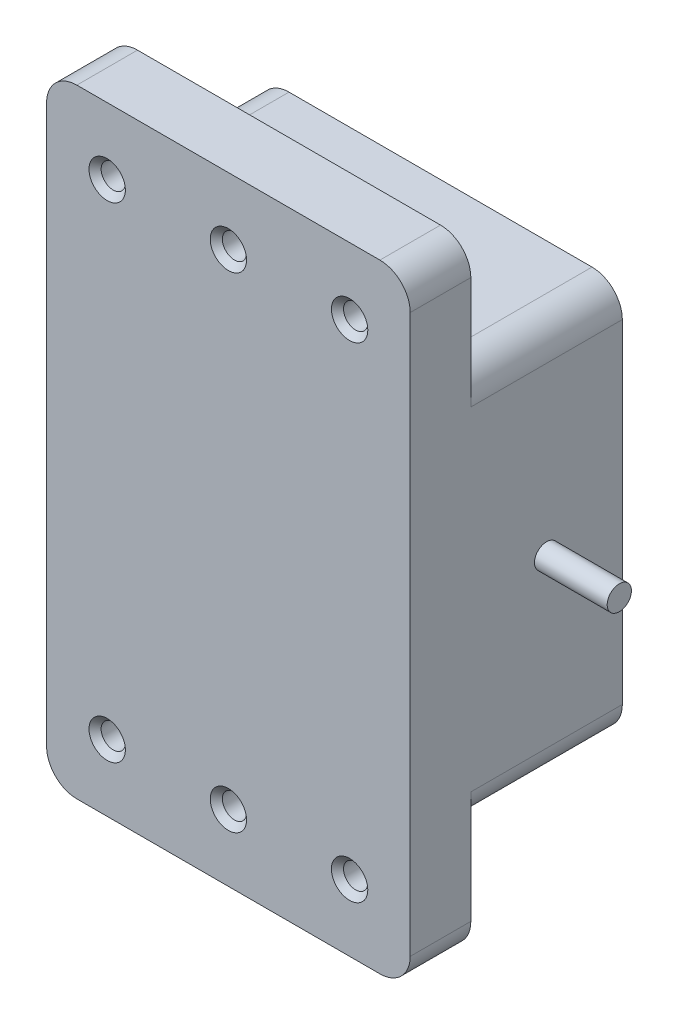
from build123d import *

# Parameters (mm, degrees)
SKETCH3_W           = 60
SKETCH3_H           = 102
SKETCH3_R           = 2
BOSS_EXTRUDE1_DEPTH = 10
SKETCH4_W           = 60
SKETCH4_H           = 65
BOSS_EXTRUDE2_DEPTH = 25
FILLET1_R           = 5
SKETCH6_W           = 3.461538462
SKETCH6_H           = 1.666666666
CUT_EXTRUDE1_DEPTH  = 2
SKETCH7_R           = 2
BOSS_EXTRUDE3_DEPTH = 12
SKETCH8_R           = 2
BOSS_EXTRUDE4_DEPTH = 12
CHAMFER2_SIZE       = 1


with BuildPart() as part:
    # Sketch3 → Boss-Extrude1 (new body)
    with BuildSketch(Plane.XY):
        Rectangle(SKETCH3_W, SKETCH3_H)
        with Locations((-20, 40)):
            Circle(SKETCH3_R, mode=Mode.SUBTRACT)
        with Locations((20, 40)):
            Circle(SKETCH3_R, mode=Mode.SUBTRACT)
        with Locations((20, -40)):
            Circle(SKETCH3_R, mode=Mode.SUBTRACT)
        with Locations((-20, -40)):
            Circle(SKETCH3_R, mode=Mode.SUBTRACT)
        with Locations((0, 40)):
            Circle(SKETCH3_R, mode=Mode.SUBTRACT)
        with Locations((0, -40)):
            Circle(SKETCH3_R, mode=Mode.SUBTRACT)
    extrude(amount=BOSS_EXTRUDE1_DEPTH)

    # Sketch4 → Boss-Extrude2 (add)
    with BuildSketch(Plane(origin=(0, 0, 0), x_dir=(-1, 0, 0), z_dir=(0, 0, -1))):
        Rectangle(SKETCH4_W, SKETCH4_H)
    extrude(amount=BOSS_EXTRUDE2_DEPTH)

    # Fillet1
    fillet1_edges = [part.edges().sort_by_distance(p)[0] for p in [
        (30, -32.5, -12.5),
        (-30, -32.5, -12.5),
        (-30, 32.5, -12.5),
        (30, 32.5, -12.5),
        (30, -51, 5),
        (-30, -51, 5),
        (-30, 51, 5),
        (30, 51, 5),
    ]]
    fillet(fillet1_edges, radius=FILLET1_R)

    # Sketch6 → Cut-Extrude1 (cut)
    with BuildSketch(Plane(origin=(0, 0, -25), x_dir=(-1, 0, 0), z_dir=(0, 0, -1))):
        Polygon((-27.221554487, 5), (-25.358573718, 5), (-23.076923077, -1.975160256), (-20.779246795, 5), (-18.934294872, 5), (-17.243589744, -5), (-19.060496795, -5), (-20.128205128, 1.316105769), (-22.207532051, -5), (-23.958333333, -5), (-26.025641026, 1.316105769), (-27.091346154, -5), (-28.91025641, -5), align=None)
        Polygon((-15.576923077, 5), (-13.782051282, 5), (-13.782051282, -3.205128205), (-10.961538462, -3.205128205), (-10.961538462, -5), (-15.576923077, -5), align=None)
        Polygon((-6.344150641, 5), (-4.679487179, 5), (-0.641025641, -5), (-2.558092949, -5), (-3.335336538, -2.948717949), (-7.692307692, -2.948717949), (-8.469551282, -5), (-10.384615385, -5), align=None)
        Polygon((-5.512820513, 2.317708333), (-7.011217949, -1.153846154), (-4.014423077, -1.153846154), align=None, mode=Mode.SUBTRACT)
        with Locations((2.564102564, -1.346153846)):
            Rectangle(SKETCH6_W, SKETCH6_H)
        with BuildLine():
            Line((8.141025641, 2.564102564), (6.346153846, 2.564102564))
            add(Edge.make_bspline(
                [(6.346153846, 2.564102564), (6.358826324, 2.653821802), (6.383669876, 2.829710425), (6.443117175, 3.084353334), (6.51422256, 3.325899561), (6.602994, 3.553584178), (6.707108457, 3.767812766), (6.825507203, 3.969320453), (6.959470174, 4.157242331), (7.06215421, 4.270447216), (7.11338141, 4.326923077)],
                knots=[0, 0, 0, 0, 0.000271706, 0.000532661, 0.00078363, 0.001026547, 0.001264861, 0.001497449, 0.001727058, 0.001955643, 0.001955643, 0.001955643, 0.001955643], degree=3))
            add(Edge.make_bspline(
                [(7.11338141, 4.326923077), (7.187269858, 4.401438883), (7.332896225, 4.548301705), (7.576254962, 4.736416757), (7.831339862, 4.899217542), (8.103266763, 5.028287182), (8.387804278, 5.132754103), (8.687215149, 5.202924769), (9.000275873, 5.249483626), (9.213900433, 5.254069836), (9.322916667, 5.256410256)],
                knots=[0, 0, 0, 0, 0.00031451, 0.000619865, 0.00092054, 0.001220686, 0.001521047, 0.001828113, 0.002141722, 0.002468545, 0.002468545, 0.002468545, 0.002468545], degree=3))
            add(Edge.make_bspline(
                [(9.322916667, 5.256410256), (9.419837707, 5.254122141), (9.610364943, 5.249624166), (9.890392039, 5.213516866), (10.157374441, 5.150188683), (10.41413423, 5.067388504), (10.656895307, 4.954725023), (10.891015643, 4.823946701), (11.109953909, 4.663541655), (11.314222379, 4.482300095), (11.501881927, 4.286269605), (11.664395918, 4.076729133), (11.804112112, 3.859275988), (11.919219775, 3.632103545), (12.007721927, 3.394827401), (12.069145044, 3.148818268), (12.109347966, 2.894618984), (12.113353228, 2.721843154), (12.115384615, 2.634214744)],
                knots=[0, 0, 0, 0, 0.000290713, 0.000571484, 0.000845052, 0.00111301, 0.001379263, 0.001646614, 0.001916281, 0.002191603, 0.002465076, 0.002729142, 0.002985873, 0.003239403, 0.00349168, 0.003743837, 0.003999094, 0.004261789, 0.004261789, 0.004261789, 0.004261789], degree=3))
            add(Edge.make_bspline(
                [(12.115384615, 2.634214744), (12.111216086, 2.525694254), (12.103009534, 2.312050773), (12.035668833, 1.999367667), (11.930262324, 1.700386816), (11.77799237, 1.419291414), (11.587616144, 1.156846443), (11.354030891, 0.921826227), (11.083889725, 0.710545967), (10.881091154, 0.59700393), (10.77724359, 0.538862179)],
                knots=[0, 0, 0, 0, 0.000325266, 0.00064035, 0.000955261, 0.001273418, 0.001595958, 0.001924594, 0.002264384, 0.002620988, 0.002620988, 0.002620988, 0.002620988], degree=3))
            add(Edge.make_bspline(
                [(10.77724359, 0.538862179), (10.848522965, 0.51545966), (10.988583739, 0.469474759), (11.18766329, 0.378908016), (11.376965194, 0.279933578), (11.553229741, 0.164951371), (11.718210095, 0.038610767), (11.870900517, -0.10016824), (12.012213295, -0.251083047), (12.139841556, -0.414963628), (12.253116625, -0.589189032), (12.354752312, -0.769734755), (12.438404148, -0.959338807), (12.509267668, -1.15583578), (12.563219117, -1.360991686), (12.601205758, -1.574011564), (12.623162969, -1.7944095), (12.626511818, -1.943728968), (12.628205128, -2.019230769)],
                knots=[0, 0, 0, 0, 0.000224904, 0.000441926, 0.000655208, 0.00086524, 0.001072385, 0.001278014, 0.001483525, 0.001691897, 0.00190025, 0.002106492, 0.002312735, 0.002521193, 0.002732558, 0.002948282, 0.003169733, 0.003396237, 0.003396237, 0.003396237, 0.003396237], degree=3))
            add(Edge.make_bspline(
                [(12.628205128, -2.019230769), (12.624772561, -2.130187762), (12.618004239, -2.348972354), (12.574974411, -2.671219668), (12.494860625, -2.978453852), (12.389466501, -3.274210098), (12.248882179, -3.554670302), (12.083438067, -3.826270641), (11.880074011, -4.079592092), (11.654069782, -4.321331816), (11.40307891, -4.54111075), (11.130963973, -4.731649195), (10.843708544, -4.895165082), (10.539495241, -5.027911938), (10.218429753, -5.130142199), (9.881227708, -5.204038944), (9.526472274, -5.249250196), (9.284323935, -5.253989738), (9.160657051, -5.256410256)],
                knots=[0, 0, 0, 0, 0.000332918, 0.000656446, 0.000972737, 0.00128388, 0.00159654, 0.001912291, 0.002236099, 0.002569119, 0.002904176, 0.003234856, 0.003564077, 0.003894193, 0.004228686, 0.00457329, 0.004928598, 0.005299456, 0.005299456, 0.005299456, 0.005299456], degree=3))
            add(Edge.make_bspline(
                [(9.160657051, -5.256410256), (9.043670174, -5.253858229), (8.814917815, -5.248868078), (8.480319616, -5.205675789), (8.162315699, -5.136003121), (7.860094514, -5.037793719), (7.574825329, -4.910432908), (7.303921214, -4.758774758), (7.052788001, -4.574071982), (6.818627569, -4.36466241), (6.606634306, -4.12971676), (6.417162251, -3.874677432), (6.254389298, -3.598574616), (6.117647912, -3.302587938), (6.008007102, -2.986198148), (5.921522752, -2.650048641), (5.861112019, -2.293482685), (5.842713803, -2.048157722), (5.833333333, -1.923076923)],
                knots=[0, 0, 0, 0, 0.000350841, 0.000686024, 0.001010203, 0.001326309, 0.001637503, 0.001946101, 0.002255828, 0.002570745, 0.002887004, 0.003203517, 0.003522335, 0.003846787, 0.00418003, 0.004525477, 0.004887076, 0.00526322, 0.00526322, 0.00526322, 0.00526322], degree=3))
            Line((5.833333333, -1.923076923), (7.628205128, -1.923076923))
            add(Edge.make_bspline(
                [(7.628205128, -1.923076923), (7.639579044, -1.985969191), (7.661732727, -2.108468375), (7.704942127, -2.285819962), (7.761250003, -2.449526431), (7.826355918, -2.6010428), (7.896680108, -2.742358427), (7.981648545, -2.868254176), (8.075035191, -2.982148633), (8.209792801, -3.117547618), (8.402438087, -3.256664424), (8.662573045, -3.377563545), (8.951948551, -3.448425284), (9.15425089, -3.457070199), (9.258814103, -3.461538462)],
                knots=[0, 0, 0, 0, 0.000191723, 0.00037343, 0.000547005, 0.000710349, 0.000868031, 0.001019707, 0.00116488, 0.001309361, 0.001591842, 0.001872362, 0.00216533, 0.002478753, 0.002478753, 0.002478753, 0.002478753], degree=3))
            add(Edge.make_bspline(
                [(9.258814103, -3.461538462), (9.314299039, -3.460586987), (9.422981617, -3.458723261), (9.582620141, -3.438066358), (9.734698312, -3.404044422), (9.879499384, -3.357809872), (10.017945169, -3.299851973), (10.147390523, -3.22511873), (10.270473864, -3.138230667), (10.385857166, -3.040545418), (10.492473715, -2.934103464), (10.581184953, -2.816237085), (10.662260606, -2.696463778), (10.722224743, -2.566947549), (10.774766245, -2.434657757), (10.806924329, -2.294792697), (10.831205991, -2.15028636), (10.832617144, -2.051392567), (10.833333333, -2.001201923)],
                knots=[0, 0, 0, 0, 0.000166375, 0.000325891, 0.000481896, 0.000633307, 0.000781396, 0.000931222, 0.001080726, 0.001232824, 0.001384394, 0.001531449, 0.001674801, 0.001817254, 0.001958632, 0.002100987, 0.002246891, 0.002397252, 0.002397252, 0.002397252, 0.002397252], degree=3))
            add(Edge.make_bspline(
                [(10.833333333, -2.001201923), (10.831431985, -1.946309903), (10.827646836, -1.837032468), (10.796721775, -1.677565029), (10.747884566, -1.524170206), (10.680043718, -1.377527302), (10.589449827, -1.238176814), (10.482550045, -1.103322949), (10.350922439, -0.979984611), (10.206509327, -0.858068402), (10.03904685, -0.751794237), (9.856690664, -0.653718798), (9.654648168, -0.575681027), (9.437851399, -0.505978843), (9.202199442, -0.45506945), (8.94915561, -0.418104269), (8.6791281, -0.390589421), (8.492994627, -0.386641963), (8.397435897, -0.384615385)],
                knots=[0, 0, 0, 0, 0.000164568, 0.000327617, 0.000485362, 0.000646679, 0.000810612, 0.000982992, 0.001161491, 0.001350781, 0.001549139, 0.001755235, 0.001970987, 0.002197801, 0.002437893, 0.002693151, 0.002964834, 0.003251468, 0.003251468, 0.003251468, 0.003251468], degree=3))
            Line((8.397435897, -0.384615385), (8.397435897, 1.282051282))
            add(Edge.make_bspline(
                [(8.397435897, 1.282051282), (8.516412199, 1.292183685), (8.738993298, 1.311139403), (9.047947797, 1.35546801), (9.30804766, 1.414720491), (9.52554439, 1.486205403), (9.706139739, 1.578010653), (9.863906839, 1.679359596), (9.999783328, 1.797061581), (10.114617189, 1.927606751), (10.206480704, 2.067800022), (10.271496349, 2.215462376), (10.314429283, 2.366024956), (10.318497176, 2.469005223), (10.320512821, 2.520032051)],
                knots=[0, 0, 0, 0, 0.000358193, 0.000670108, 0.000935418, 0.001157773, 0.001354863, 0.001541548, 0.001719066, 0.001892248, 0.002061717, 0.002219552, 0.002375042, 0.002527759, 0.002527759, 0.002527759, 0.002527759], degree=3))
            add(Edge.make_bspline(
                [(10.320512821, 2.520032051), (10.317035256, 2.585136744), (10.310247787, 2.71220732), (10.257532624, 2.894072083), (10.166025073, 3.056189446), (10.043329515, 3.198218268), (9.893820712, 3.316851385), (9.718570185, 3.402977005), (9.521380882, 3.453579652), (9.382647582, 3.458825442), (9.310897436, 3.461538462)],
                knots=[0, 0, 0, 0, 0.000195145, 0.000380883, 0.000562026, 0.000749537, 0.000940694, 0.001130618, 0.001331279, 0.00154622, 0.00154622, 0.00154622, 0.00154622], degree=3))
            add(Edge.make_bspline(
                [(9.310897436, 3.461538462), (9.245863995, 3.458337384), (9.11681773, 3.451985465), (8.928113466, 3.404576425), (8.748907284, 3.324769206), (8.582910039, 3.214719755), (8.432517936, 3.082555029), (8.309089409, 2.926033344), (8.206427412, 2.754532186), (8.162911696, 2.62782795), (8.141025641, 2.564102564)],
                knots=[0, 0, 0, 0, 0.000194971, 0.000386881, 0.0005797, 0.00078083, 0.000982289, 0.001177506, 0.001376783, 0.001578421, 0.001578421, 0.001578421, 0.001578421], degree=3))
        make_face()
        with BuildLine():
            add(Edge.make_bspline(
                [(16.893028846, 5.256410256), (16.979908091, 5.25512051), (17.150735898, 5.252584523), (17.402333102, 5.225117718), (17.644690772, 5.183623037), (17.87875704, 5.125752427), (18.102847075, 5.049162735), (18.31859185, 4.957486187), (18.523423378, 4.845914159), (18.719953914, 4.719887823), (18.908107757, 4.577208144), (19.083362758, 4.414545944), (19.248919448, 4.235644086), (19.401194133, 4.037797895), (19.543558983, 3.822806991), (19.675546211, 3.590637284), (19.796145421, 3.34015246), (19.906708244, 3.070900497), (20.005573869, 2.778845426), (20.088848263, 2.460637248), (20.16026999, 2.116203294), (20.220554967, 1.744686217), (20.266120666, 1.345592182), (20.296832864, 0.919186326), (20.317909028, 0.466290698), (20.319629118, 0.155608018), (20.320512821, -0.00400641)],
                knots=[0, 0, 0, 0, 0.00026054, 0.000512291, 0.000758302, 0.000997826, 0.001234746, 0.001468058, 0.001700196, 0.001933576, 0.002167959, 0.00240755, 0.002649971, 0.002898401, 0.003155639, 0.00342299, 0.003698938, 0.003989099, 0.0042957, 0.004623198, 0.004975216, 0.00535065, 0.005751941, 0.006179826, 0.006632994, 0.007111797, 0.007111797, 0.007111797, 0.007111797], degree=3))
            add(Edge.make_bspline(
                [(20.320512821, -0.00400641), (20.319557777, -0.165617794), (20.317702144, -0.479625815), (20.297709006, -0.936663857), (20.263279879, -1.366165675), (20.218905135, -1.768086835), (20.158123874, -2.142215088), (20.086940569, -2.489519175), (20.002351714, -2.809873207), (19.900229486, -3.102555358), (19.790335903, -3.372280186), (19.669406802, -3.622276625), (19.53954996, -3.853221803), (19.403743902, -4.068599844), (19.254543241, -4.26206151), (19.099209994, -4.440185512), (18.930980672, -4.596186876), (18.756938381, -4.738105214), (18.570707249, -4.860751138), (18.374207827, -4.968015241), (18.163936873, -5.055019168), (17.943727267, -5.130690538), (17.709825493, -5.185014416), (17.465948218, -5.228118628), (17.209342117, -5.251940659), (17.034634347, -5.254895939), (16.945112179, -5.256410256)],
                knots=[0, 0, 0, 0, 0.000484813, 0.000941983, 0.001372019, 0.001777291, 0.002154702, 0.002508681, 0.002840566, 0.003147815, 0.003437976, 0.003713924, 0.00398029, 0.004232567, 0.004476966, 0.004712528, 0.004940691, 0.005164379, 0.005385504, 0.005608688, 0.0058349, 0.006067384, 0.006306429, 0.006554414, 0.006809954, 0.007078503, 0.007078503, 0.007078503, 0.007078503], degree=3))
            add(Edge.make_bspline(
                [(16.945112179, -5.256410256), (16.855592428, -5.254866729), (16.680224552, -5.25184298), (16.422924562, -5.228295755), (16.17775486, -5.1848398), (15.942002547, -5.130273479), (15.717308423, -5.055186599), (15.502595085, -4.965579576), (15.299513494, -4.858984748), (15.107501348, -4.73605307), (14.927214232, -4.595084274), (14.755850485, -4.437586177), (14.593789173, -4.263957998), (14.443495652, -4.072254957), (14.302508547, -3.865035889), (14.172298132, -3.639934455), (14.052942659, -3.397278396), (13.940708667, -3.136729474), (13.843191535, -2.852678371), (13.756405816, -2.542588545), (13.685313237, -2.203875143), (13.628135828, -1.836646979), (13.582485418, -1.441682043), (13.548526759, -1.018789697), (13.528422569, -0.567772966), (13.526586397, -0.257766701), (13.525641026, -0.098157051)],
                knots=[0, 0, 0, 0, 0.000268549, 0.000526084, 0.000774069, 0.001015062, 0.001251347, 0.001483874, 0.001712362, 0.001938521, 0.002166921, 0.00239802, 0.00263614, 0.002878603, 0.003128072, 0.003387478, 0.003658029, 0.003938949, 0.004237971, 0.004558265, 0.004904402, 0.005275563, 0.005672875, 0.006096921, 0.006548087, 0.007026891, 0.007026891, 0.007026891, 0.007026891], degree=3))
            add(Edge.make_bspline(
                [(13.525641026, -0.098157051), (13.527353477, 0.123607992), (13.530657673, 0.551506501), (13.572530874, 1.169695434), (13.633990113, 1.741104017), (13.724259176, 2.264776424), (13.835875624, 2.742652185), (13.978806298, 3.171583304), (14.141522473, 3.557505006), (14.280177559, 3.786127345), (14.346955128, 3.896233974)],
                knots=[0, 0, 0, 0, 0.000665173, 0.001283459, 0.00185796, 0.002388511, 0.002876808, 0.003328472, 0.003743813, 0.004129683, 0.004129683, 0.004129683, 0.004129683], degree=3))
            add(Edge.make_bspline(
                [(14.346955128, 3.896233974), (14.424600905, 4.004402693), (14.576413699, 4.215893852), (14.841862613, 4.493542211), (15.12705291, 4.731000684), (15.437842236, 4.922895372), (15.769315328, 5.074223538), (16.124318053, 5.181104918), (16.501539443, 5.24337899), (16.760583664, 5.252001635), (16.893028846, 5.256410256)],
                knots=[0, 0, 0, 0, 0.00039904, 0.000780202, 0.001148776, 0.001509542, 0.001872614, 0.0022389, 0.002618611, 0.003015858, 0.003015858, 0.003015858, 0.003015858], degree=3))
        make_face()
        with BuildLine():
            add(Edge.make_bspline(
                [(16.937099359, 3.461538462), (16.858559802, 3.457815843), (16.704580578, 3.450517534), (16.481149387, 3.388565186), (16.270467725, 3.292876446), (16.110207812, 3.177730007), (15.99025486, 3.067348338), (15.906442873, 2.967456516), (15.825619421, 2.855984443), (15.754232078, 2.727901956), (15.686823792, 2.587811211), (15.620945577, 2.435076279), (15.56694274, 2.265945661), (15.513886385, 2.083299672), (15.467404067, 1.882088636), (15.428462074, 1.660667874), (15.393670827, 1.417597468), (15.369403517, 1.152718206), (15.346779102, 0.866307217), (15.33056085, 0.557726488), (15.323780405, 0.227059267), (15.321625108, -0.00066634), (15.320512821, -0.118189103)],
                knots=[0, 0, 0, 0, 0.00023523, 0.000461175, 0.000690627, 0.000926291, 0.001049598, 0.001178879, 0.001316736, 0.00146209, 0.00161798, 0.001783168, 0.001960539, 0.002150126, 0.002353725, 0.002579661, 0.002824429, 0.003090132, 0.003377436, 0.003686346, 0.004016972, 0.004369559, 0.004369559, 0.004369559, 0.004369559], degree=3))
            add(Edge.make_bspline(
                [(15.320512821, -0.118189103), (15.322343511, -0.270445522), (15.325853997, -0.562408496), (15.34424028, -0.982261419), (15.381094059, -1.364361386), (15.426932719, -1.711298031), (15.491314989, -2.020821376), (15.565390958, -2.295859799), (15.656868193, -2.532907229), (15.762587764, -2.735391904), (15.879676953, -2.907645196), (16.006782418, -3.054061271), (16.139576674, -3.180850683), (16.282204661, -3.28384016), (16.434326112, -3.362766548), (16.594671092, -3.419537325), (16.763341498, -3.454289081), (16.878845253, -3.459108032), (16.937099359, -3.461538462)],
                knots=[0, 0, 0, 0, 0.000456801, 0.00087595, 0.001260257, 0.001608147, 0.001925191, 0.002208062, 0.002461766, 0.002685776, 0.002891912, 0.003085073, 0.003266471, 0.003441588, 0.003610927, 0.003778827, 0.003950507, 0.0041252, 0.0041252, 0.0041252, 0.0041252], degree=3))
            add(Edge.make_bspline(
                [(16.937099359, -3.461538462), (16.993354369, -3.459875381), (17.103494682, -3.456619277), (17.264103927, -3.423195803), (17.415987441, -3.368856495), (17.55868664, -3.291989728), (17.692711941, -3.194241873), (17.817408309, -3.075183385), (17.93183531, -2.933627527), (17.998501001, -2.828572144), (18.032852564, -2.774439103)],
                knots=[0, 0, 0, 0, 0.000168567, 0.000330033, 0.000489713, 0.00065103, 0.000814509, 0.000985956, 0.001166789, 0.001359023, 0.001359023, 0.001359023, 0.001359023], degree=3))
            add(Edge.make_bspline(
                [(18.032852564, -2.774439103), (18.073295744, -2.700468031), (18.158101814, -2.545356693), (18.256239544, -2.283612093), (18.338846415, -1.988407445), (18.409944941, -1.658824043), (18.458571996, -1.293561971), (18.500449556, -0.894937386), (18.520648144, -0.460942977), (18.523933554, -0.160270085), (18.525641026, -0.00400641)],
                knots=[0, 0, 0, 0, 0.000252658, 0.000529804, 0.000836058, 0.001171982, 0.001540267, 0.001940913, 0.002374166, 0.002842984, 0.002842984, 0.002842984, 0.002842984], degree=3))
            add(Edge.make_bspline(
                [(18.525641026, -0.00400641), (18.524981466, 0.153613708), (18.523711928, 0.45700553), (18.500419565, 0.892560179), (18.46798317, 1.290367065), (18.420538088, 1.649538046), (18.359491367, 1.970945032), (18.284251053, 2.254567012), (18.195548319, 2.50096295), (18.090357448, 2.709887157), (17.973852023, 2.887444073), (17.850177958, 3.039774134), (17.718812308, 3.169829697), (17.579974759, 3.278100184), (17.430451869, 3.360826957), (17.273099719, 3.419238902), (17.107595725, 3.454576169), (16.994698571, 3.459186373), (16.937099359, 3.461538462)],
                knots=[0, 0, 0, 0, 0.000472795, 0.000910049, 0.001308143, 0.001669925, 0.001996398, 0.002288928, 0.002549414, 0.002780548, 0.0029889, 0.003185378, 0.003368109, 0.0035424, 0.003711869, 0.003878569, 0.004044364, 0.004217058, 0.004217058, 0.004217058, 0.004217058], degree=3))
        make_face(mode=Mode.SUBTRACT)
        Polygon((24.166666667, 0.641025641), (24.166666667, 3.076923077), (25.833333333, 3.076923077), (25.833333333, 0.641025641), (28.397435897, 0.641025641), (28.397435897, -1.025641026), (25.833333333, -1.025641026), (25.833333333, -3.461538462), (24.166666667, -3.461538462), (24.166666667, -1.025641026), (21.602564103, -1.025641026), (21.602564103, 0.641025641), align=None)
    extrude(amount=-CUT_EXTRUDE1_DEPTH, mode=Mode.SUBTRACT)

    # Sketch7 → Boss-Extrude3 (add)
    with BuildSketch(Plane(origin=(30, 0, 0), x_dir=(0, 0, -1), z_dir=(1, 0, 0))):
        with Locations((12.5, 0)):
            Circle(SKETCH7_R)
    extrude(amount=BOSS_EXTRUDE3_DEPTH)

    # Sketch8 → Boss-Extrude4 (add)
    with BuildSketch(Plane.ZY.offset(30)):
        with Locations((-12.5, 0)):
            Circle(SKETCH8_R)
    extrude(amount=BOSS_EXTRUDE4_DEPTH)

    # Chamfer2
    chamfer2_edges = [part.edges().sort_by_distance(p)[0] for p in [
        (-22, 40, 10),
        (18, 40, 10),
        (18, -40, 10),
        (-22, -40, 10),
        (-2, 40, 10),
        (-2, -40, 10),
    ]]
    chamfer(chamfer2_edges, length=CHAMFER2_SIZE)


solid = part.part
